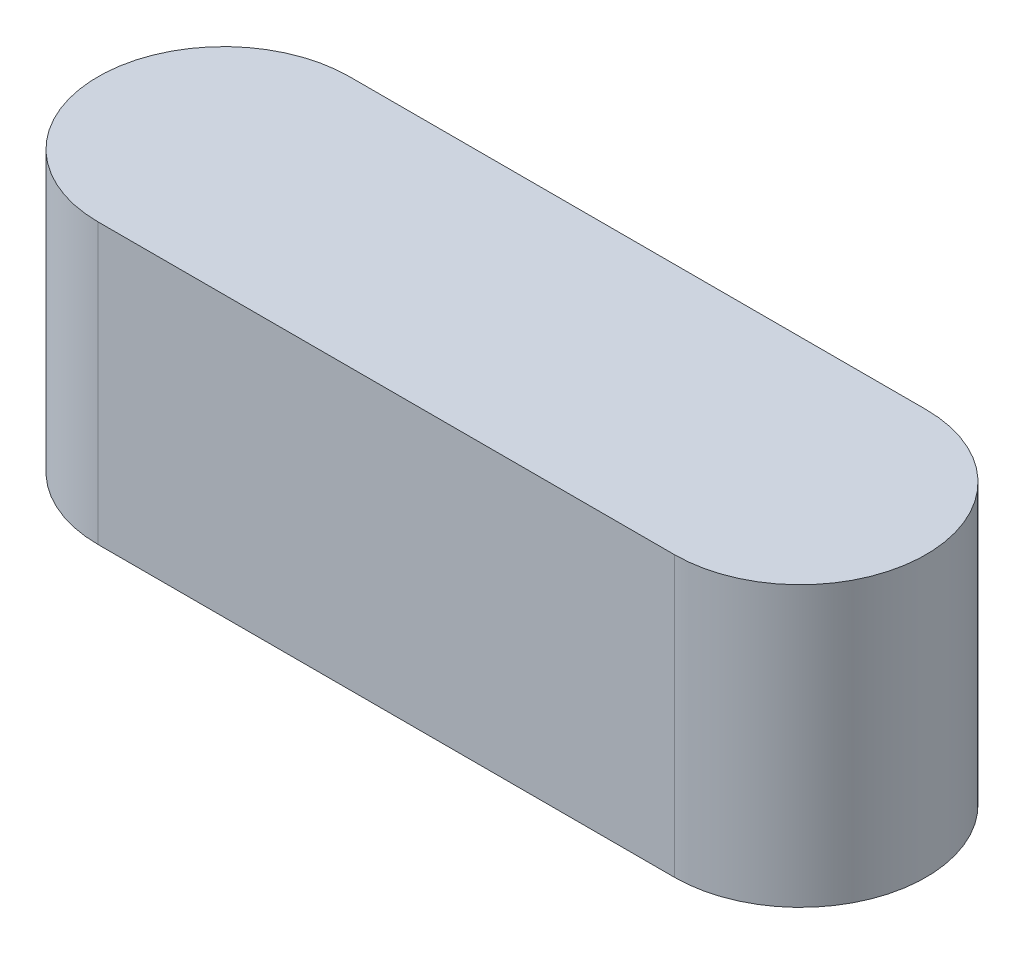
from build123d import *

# Parameters (mm, degrees)
EXTRUDE_1_DEPTH = 27
SKETCH_2_W      = 15
SKETCH_2_H      = 8
EXTRUDE_2_DEPTH = 5


with BuildPart() as part:
    # 草图1 → 凸台-拉伸1 (new body)
    with BuildSketch(Plane(origin=(0, 0, 0), x_dir=(1, 0, 0), z_dir=(0, 1, 0))):
        with BuildLine():
            Line((0, 12.15), (55.7, 12.15))
            ThreePointArc((55.7, 12.15), (67.85, 0), (55.7, -12.15))
            Line((55.7, -12.15), (0, -12.15))
            ThreePointArc((0, -12.15), (-12.15, 0), (0, 12.15))
        make_face()
    extrude(amount=EXTRUDE_1_DEPTH)

    # 草图2 → 凸台-拉伸2 (add)
    with BuildSketch(Plane.XZ):
        with Locations((27.85, -4.85)):
            Rectangle(SKETCH_2_W, SKETCH_2_H)
    extrude(amount=EXTRUDE_2_DEPTH)


solid = part.part
